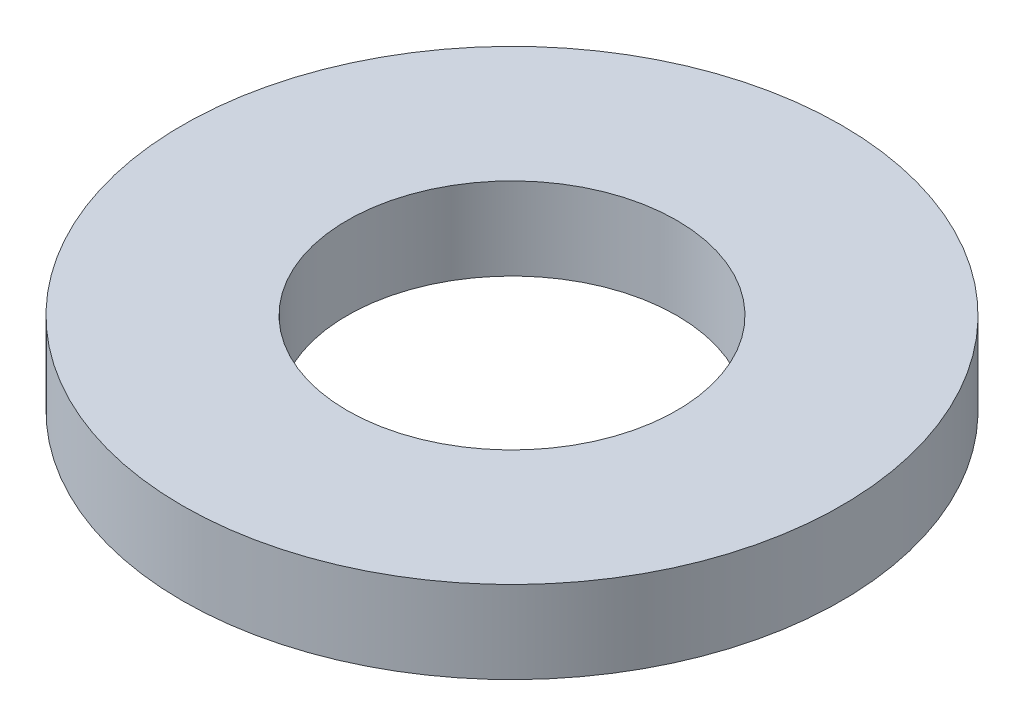
from build123d import *

# Parameters (mm, degrees)
SKETCH1_R           = 25.4
SKETCH1_R_2         = 12.7
BOSS_EXTRUDE1_DEPTH = 6.35


with BuildPart() as part:
    # Sketch1 → Boss-Extrude1 (new body)
    with BuildSketch(Plane(origin=(0, 0, 0), x_dir=(1, 0, 0), z_dir=(0, 1, 0))):
        Circle(SKETCH1_R)
        Circle(SKETCH1_R_2, mode=Mode.SUBTRACT)
    extrude(amount=BOSS_EXTRUDE1_DEPTH)


solid = part.part
